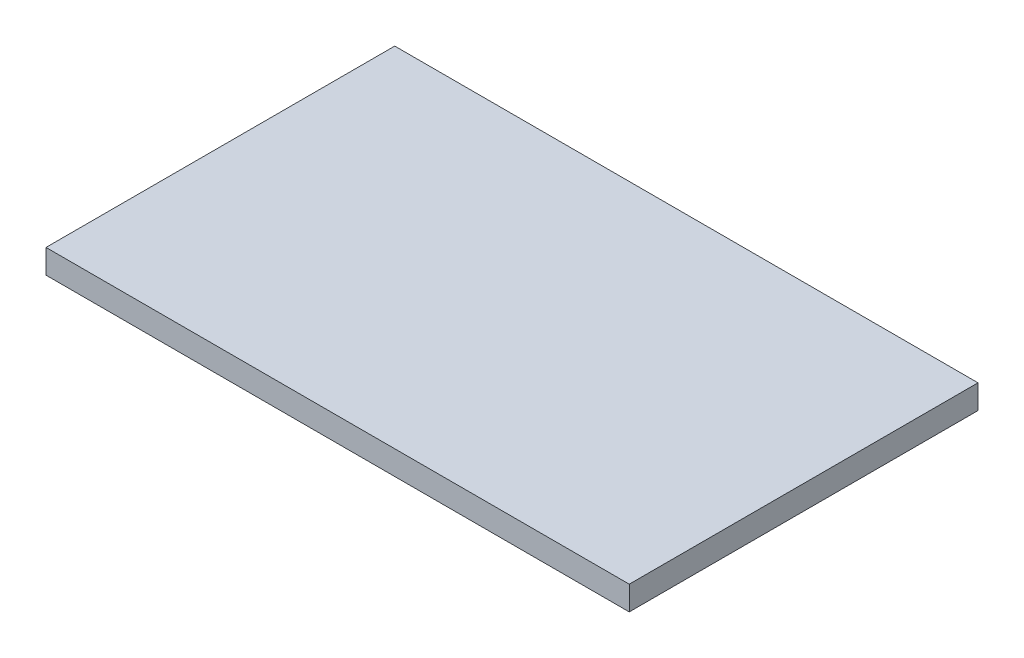
from build123d import *

# Parameters (mm, degrees)
SKETCH1_W           = 48.5
SKETCH1_H           = 29
BOSS_EXTRUDE1_DEPTH = 2


with BuildPart() as part:
    # Sketch1 → Boss-Extrude1 (new body)
    with BuildSketch(Plane(origin=(0, 0, 0), x_dir=(1, 0, 0), z_dir=(0, 1, 0))):
        with Locations((24.25, -14.5)):
            Rectangle(SKETCH1_W, SKETCH1_H)
    extrude(amount=BOSS_EXTRUDE1_DEPTH)


solid = part.part
